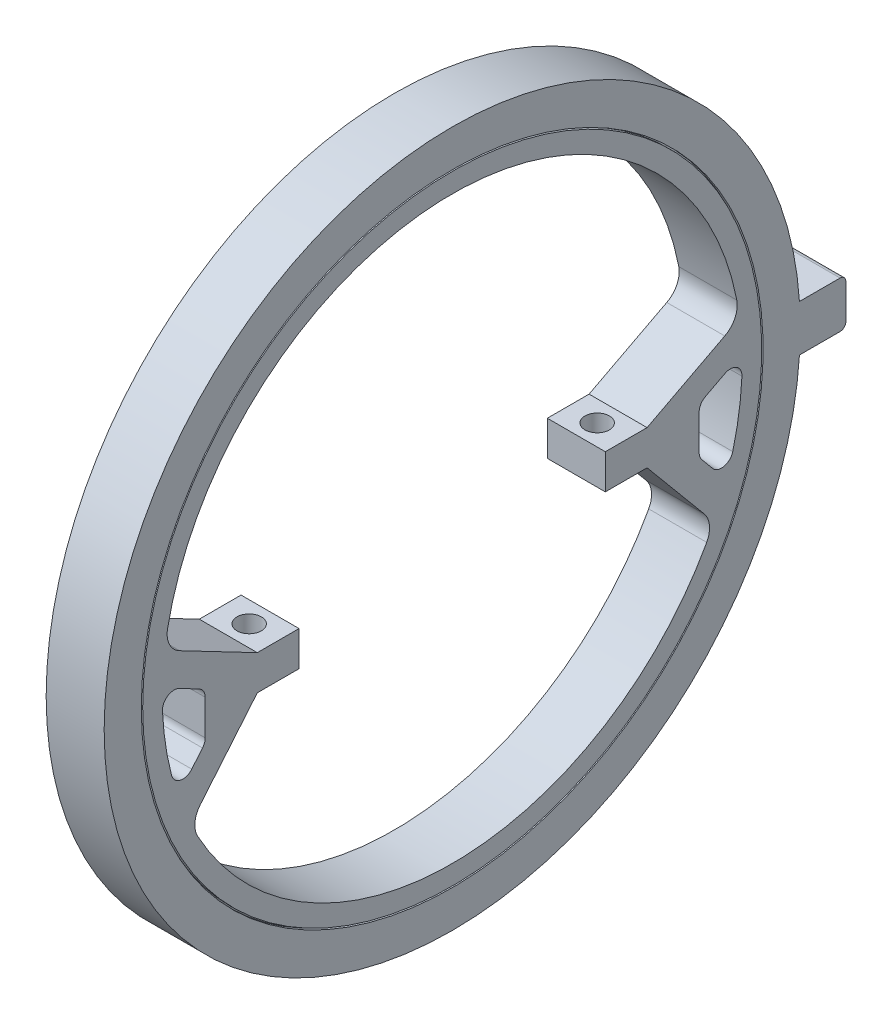
from build123d import *

# Parameters (mm, degrees)
REVOLVE2_ANGLE      = 180
BOSS_EXTRUDE1_DEPTH = 2.5
FILLET1_R           = 2
FILLET2_R           = 1
CUT_EXTRUDE1_REACH  = 44.5
SKETCH4_R           = 1.05
SKETCH5_W           = 4
SKETCH5_H           = 4
BOSS_EXTRUDE2_DEPTH = 2.5
FILLET3_R           = 0.5


with BuildPart() as part:
    # Sketch2 → Revolve1 (revolve)
    with BuildSketch(Plane(origin=(0, 0, 0), x_dir=(1, 0, 0), z_dir=(0, 1, 0)), mode=Mode.PRIVATE) as revolve1_sk:
        Polygon((-1.25, 28.5), (0, 28.5), (0, 30), (-2.5, 30), (-2.5, 26.8), (-2.231495458, 26.8), align=None)
    revolve1 = revolve(revolve1_sk.sketch.rotate(Axis((0, 0, 0), (1, 0, 0)), 180), axis=Axis((0, 0, 0), (1, 0, 0)))


with BuildPart() as body_2:
    # Sketch2_3 → Revolve2 (revolve, symmetric)
    with BuildSketch(Plane(origin=(0, 0, 0), x_dir=(1, 0, 0), z_dir=(0, 1, 0))) as revolve2_sk:
        Polygon((-2.5, 25), (0, 25), (0, 28.38), (-1.180717968, 28.38), (-2.162213425, 26.68), (-2.5, 26.68), align=None)
    revolve2 = revolve(axis=Axis((0, 0, 0), (1, 0, 0)), revolution_arc=REVOLVE2_ANGLE / 2)
    revolve2 = revolve2 + revolve(revolve2_sk.sketch, axis=Axis((0, 0, 0), (-1, 0, 0)), revolution_arc=REVOLVE2_ANGLE / 2)


with BuildPart() as part_1:
    add(part.part)

    add(body_2.part)  # Mirror1 merges body 2
    # Mirror1: Revolve1, Revolve2 across plane
    add(revolve1.mirror(Plane(origin=(0, 0, 0), x_dir=(0, 0, 1), z_dir=(1, 0, 0))))
    add(revolve2.mirror(Plane(origin=(0, 0, 0), x_dir=(0, 0, 1), z_dir=(1, 0, 0))))

    # Sketch3 → Boss-Extrude1 (add, symmetric)
    with BuildSketch(Plane(origin=(0, 0, 0), x_dir=(0, 0, -1), z_dir=(1, 0, 0))):
        with BuildLine():
            Line((24.779575684, 3.312495874), (16.8, -0.85))
            Line((16.8, -0.85), (13.2, -0.85))
            Line((13.2, -0.85), (13.2, -3.85))
            Line((13.2, -3.85), (16.8, -3.85))
            Line((16.8, -3.85), (22.565633273, -10.760678184))
            ThreePointArc((22.565633273, -10.760678184), (23.138338492, -9.466640999), (23.636907605, -8.142272341))
            Line((23.636907605, -8.142272341), (21.288980036, -5.328050372))
            Line((21.288980036, -5.328050372), (21.288980036, -1.328050372))
            Line((21.288980036, -1.328050372), (24.99270325, 0.603973737))
            ThreePointArc((24.99270325, 0.603973737), (24.92296051, 1.961132171), (24.779575684, 3.312495874))
        make_face()
    extrude(amount=BOSS_EXTRUDE1_DEPTH, both=True)

    # Fillet1
    fillet1_edges = [part_1.edges().sort_by_distance(p)[0] for p in [
        (0, 3.312495874, -24.779575684),
        (0, -10.760678184, -22.565633273),
    ]]
    fillet(fillet1_edges, radius=FILLET1_R)

    # Fillet2
    fillet2_edges = [part_1.edges().sort_by_distance(p)[0] for p in [
        (0, -1.328050372, -21.288980036),
        (0, 0.603973737, -24.99270325),
        (0, -8.142272341, -23.636907605),
        (0, -5.328050372, -21.288980036),
    ]]
    fillet(fillet2_edges, radius=FILLET2_R)

    # Sketch4 → Cut-Extrude1 (cut, up to next)
    with BuildSketch(Plane(origin=(0, 0, 0), x_dir=(1, 0, 0), z_dir=(0, 1, 0)), mode=Mode.PRIVATE) as cut_extrude1_sk1:
        with Locations(Location((0, 15, 0), (0, 0, 270))):
            Circle(SKETCH4_R)
    cut_extrude1_tool1 = extrude(cut_extrude1_sk1.sketch, amount=-CUT_EXTRUDE1_REACH, mode=Mode.PRIVATE) & part_1.part
    add(cut_extrude1_tool1.solids().sort_by_distance((0, 0, -15))[0], mode=Mode.SUBTRACT)

    # Mirror2: part across plane


with BuildPart() as part_2:
    add(part_1.part)
    add(part_1.part.mirror(Plane.XY))

    # Sketch5 → Boss-Extrude2 (add, symmetric)
    with BuildSketch(Plane(origin=(0, 0, 0), x_dir=(0, 0, -1), z_dir=(1, 0, 0))):
        with Locations((31.933259094, 0)):
            Rectangle(SKETCH5_W, SKETCH5_H)
    extrude(amount=BOSS_EXTRUDE2_DEPTH, both=True)

    # Fillet3
    fillet3_edges = [part_2.edges().sort_by_distance(p)[0] for p in [
        (0, 2, -33.933259094),
        (0, -2, -33.933259094),
    ]]
    fillet(fillet3_edges, radius=FILLET3_R)


solid = part_2.part
